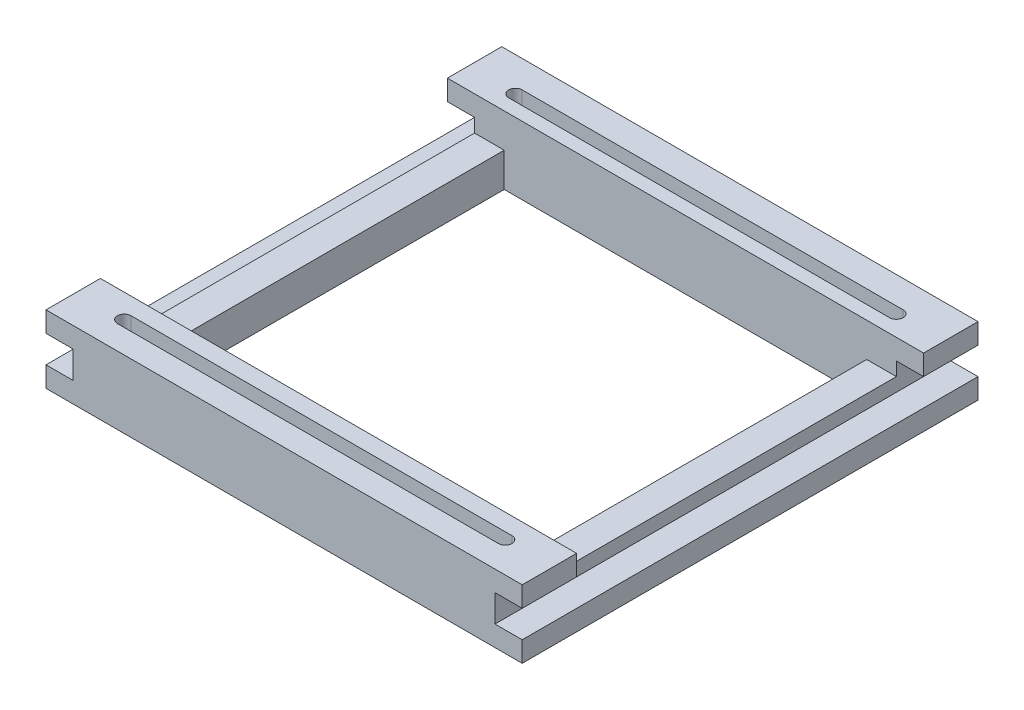
from build123d import *

# Parameters (mm, degrees)
ESQUISSE1_W             = 70
ESQUISSE1_H             = 67
ESQUISSE1_W_2           = 53.28358209
ESQUISSE1_H_2           = 51
BOSS_EXTRU_1_DEPTH      = 10
ESQUISSE2_W             = 8.358208955
ESQUISSE2_H             = 51
ENL_V_MAT_EXTRU_1_DEPTH = 5
ESQUISSE3_W             = 4
ESQUISSE3_H             = 4
ENL_V_MAT_EXTRU_2_DEPTH = 68
ENL_V_MAT_EXTRU_3_DEPTH = 5


with BuildPart() as part:
    # Esquisse1 → Boss.-Extru.1 (new body)
    with BuildSketch(Plane(origin=(0, 0, 0), x_dir=(1, 0, 0), z_dir=(0, 1, 0))):
        Rectangle(ESQUISSE1_W, ESQUISSE1_H)
        Rectangle(ESQUISSE1_W_2, ESQUISSE1_H_2, mode=Mode.SUBTRACT)
    extrude(amount=BOSS_EXTRU_1_DEPTH)

    # Esquisse2 → Enlèv. mat.-Extru.1 (cut)
    with BuildSketch(Plane(origin=(0, 10, 0), x_dir=(1, 0, 0), z_dir=(0, 1, 0))):
        with Locations((-30.820895523, 0)):
            Rectangle(ESQUISSE2_W, ESQUISSE2_H)
        with Locations((30.820895523, 0)):
            Rectangle(ESQUISSE2_W, ESQUISSE2_H)
    extrude(amount=-ENL_V_MAT_EXTRU_1_DEPTH, mode=Mode.SUBTRACT)

    # Esquisse3 → Enlèv. mat.-Extru.2 (cut, through all)
    with BuildSketch(Plane.XY.offset(33.5)):
        with Locations((33, 5)):
            Rectangle(ESQUISSE3_W, ESQUISSE3_H)
        with Locations((-33, 5)):
            Rectangle(ESQUISSE3_W, ESQUISSE3_H)
    extrude(amount=-ENL_V_MAT_EXTRU_2_DEPTH, mode=Mode.SUBTRACT)

    # Esquisse4 → Enlèv. mat.-Extru.3 (cut)
    with BuildSketch(Plane(origin=(0, 10, 0), x_dir=(1, 0, 0), z_dir=(0, 1, 0))):
        with BuildLine():
            Line((-28, 29.5), (28, 29.5))
            ThreePointArc((28, 29.5), (29, 28.5), (28, 27.5))
            Line((28, 27.5), (-28, 27.5))
            ThreePointArc((-28, 27.5), (-29, 28.5), (-28, 29.5))
        make_face()
        with BuildLine():
            Line((28, -30), (-28, -30))
            ThreePointArc((-28, -30), (-29, -29), (-28, -28))
            Line((-28, -28), (28, -28))
            ThreePointArc((28, -28), (29, -29), (28, -30))
        make_face()
    extrude(amount=-ENL_V_MAT_EXTRU_3_DEPTH, mode=Mode.SUBTRACT)


solid = part.part
